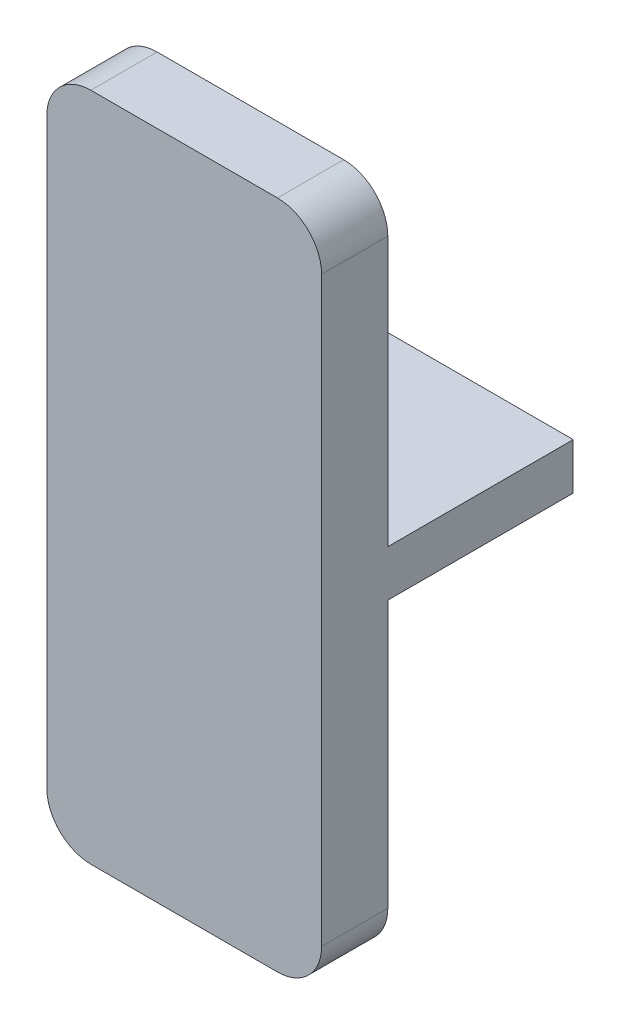
from build123d import *

# Parameters (mm, degrees)
ESQUISSE1_W        = 12.45
ESQUISSE1_H        = 2.1
BOSS_EXTRU_1_DEPTH = 8.4
ESQUISSE2_W        = 12.45
ESQUISSE2_H        = 30.368041495
BOSS_EXTRU_2_DEPTH = 3
CONG_1_R           = 2


with BuildPart() as part:
    # Esquisse1 → Boss.-Extru.1 (new body)
    with BuildSketch(Plane.XY):
        with Locations((6.225, 1.05)):
            Rectangle(ESQUISSE1_W, ESQUISSE1_H)
    extrude(amount=BOSS_EXTRU_1_DEPTH)

    # Esquisse2 → Boss.-Extru.2 (add)
    with BuildSketch(Plane.XY.offset(8.4)):
        with Locations((6.225, 1.097662534)):
            Rectangle(ESQUISSE2_W, ESQUISSE2_H)
    extrude(amount=BOSS_EXTRU_2_DEPTH)

    # Congé1
    cong_1_edges = [part.edges().sort_by_distance(p)[0] for p in [
        (12.45, -14.086358213, 9.9),
        (12.45, 16.281683282, 9.9),
        (0, 16.281683282, 9.9),
        (0, -14.086358213, 9.9),
    ]]
    fillet(cong_1_edges, radius=CONG_1_R)


solid = part.part
